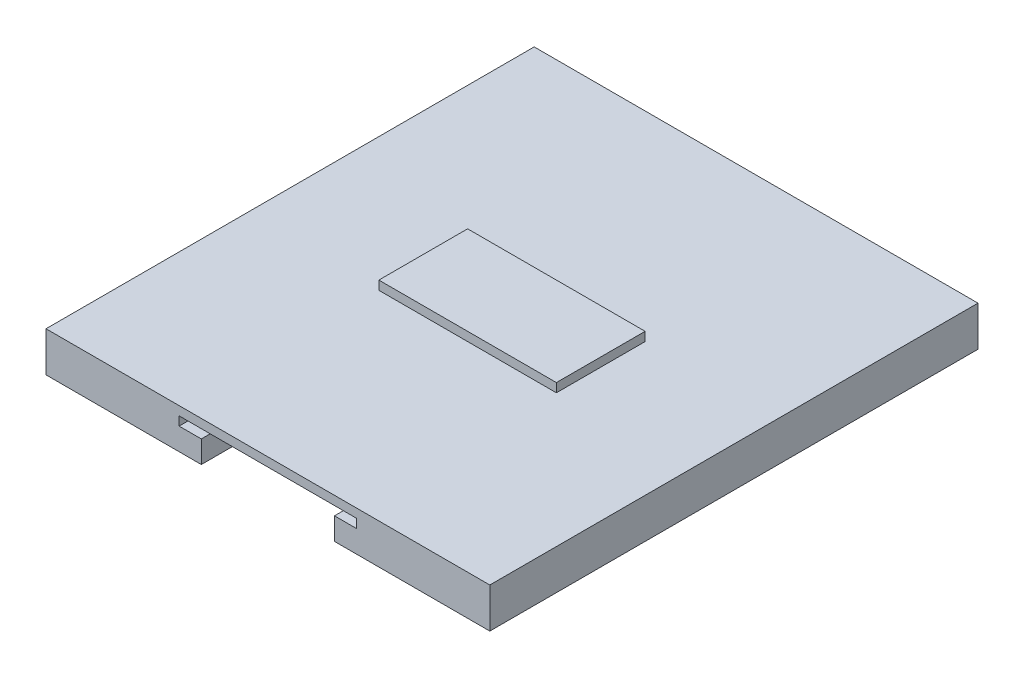
from build123d import *

# Parameters (mm, degrees)
SKETCH2_W          = 100
SKETCH2_H          = 9
EXTRUDE1_DEPTH     = 55
CUT_EXTRUDE1_DEPTH = 111
SKETCH7_W          = 40
SKETCH7_H          = 20
EXTRUDE2_DEPTH     = 2


with BuildPart() as part:
    # Sketch2 → Extrude1 (new body, symmetric)
    with BuildSketch(Plane(origin=(0, 0, 0), x_dir=(-1, 0, 0), z_dir=(0, 0, -1))):
        with Locations((0, 4.5)):
            Rectangle(SKETCH2_W, SKETCH2_H)
    extrude(amount=EXTRUDE1_DEPTH, both=True)

    # Sketch5 → Cut-Extrude1 (cut, through all)
    with BuildSketch(Plane(origin=(0, 0, -55), x_dir=(-1, 0, 0), z_dir=(0, 0, -1))):
        Polygon((20, 5), (20, 7), (-20, 7), (-20, 5), (-15, 5), (-15, 0), (15, 0), (15, 5), align=None)
    extrude(amount=-CUT_EXTRUDE1_DEPTH, mode=Mode.SUBTRACT)

    # Sketch7 → Extrude2 (add)
    with BuildSketch(Plane(origin=(0, 9, 0), x_dir=(1, 0, 0), z_dir=(0, 1, 0))):
        Rectangle(SKETCH7_W, SKETCH7_H)
    extrude(amount=EXTRUDE2_DEPTH)


solid = part.part
